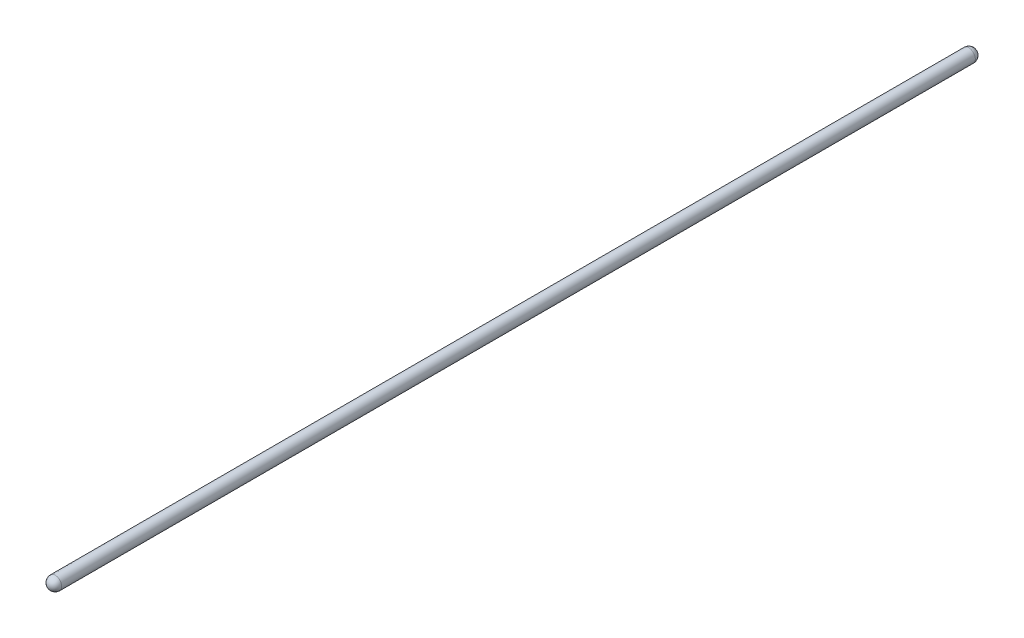
from build123d import *


with BuildPart() as part:
    # Sketch1 → Revolve1 (revolve)
    with BuildSketch(Plane(origin=(0, 0, 0), x_dir=(1, 0, 0), z_dir=(0, 1, 0))):
        with BuildLine():
            Line((9.525, 0), (9.525, -1331.03874))
            ThreePointArc((9.525, -1331.03874), (6.735192091, -1337.773932091), (0, -1340.56374))
            Line((0, -1340.56374), (0, 9.525))
            ThreePointArc((0, 9.525), (6.735192091, 6.735192091), (9.525, 0))
        make_face()
    revolve(axis=Axis((0, 0, -9.525), (0, 0, 1)))


solid = part.part
